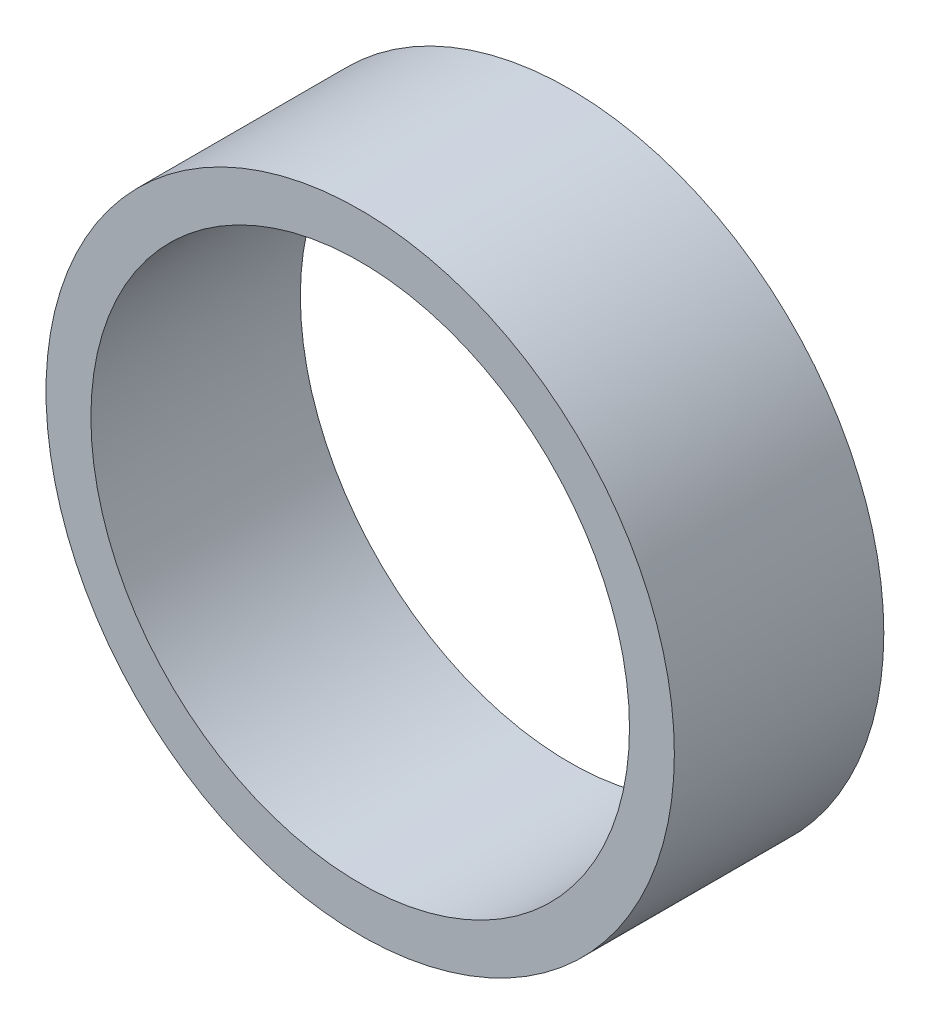
from build123d import *

# Parameters (mm, degrees)
SKETCH1_R           = 266.7
SKETCH1_R_2         = 228.6
BOSS_EXTRUDE1_DEPTH = 177.8


with BuildPart() as part:
    # Sketch1 → Boss-Extrude1 (new body)
    with BuildSketch(Plane.XY):
        Circle(SKETCH1_R)
        Circle(SKETCH1_R_2, mode=Mode.SUBTRACT)
    extrude(amount=BOSS_EXTRUDE1_DEPTH)


solid = part.part
